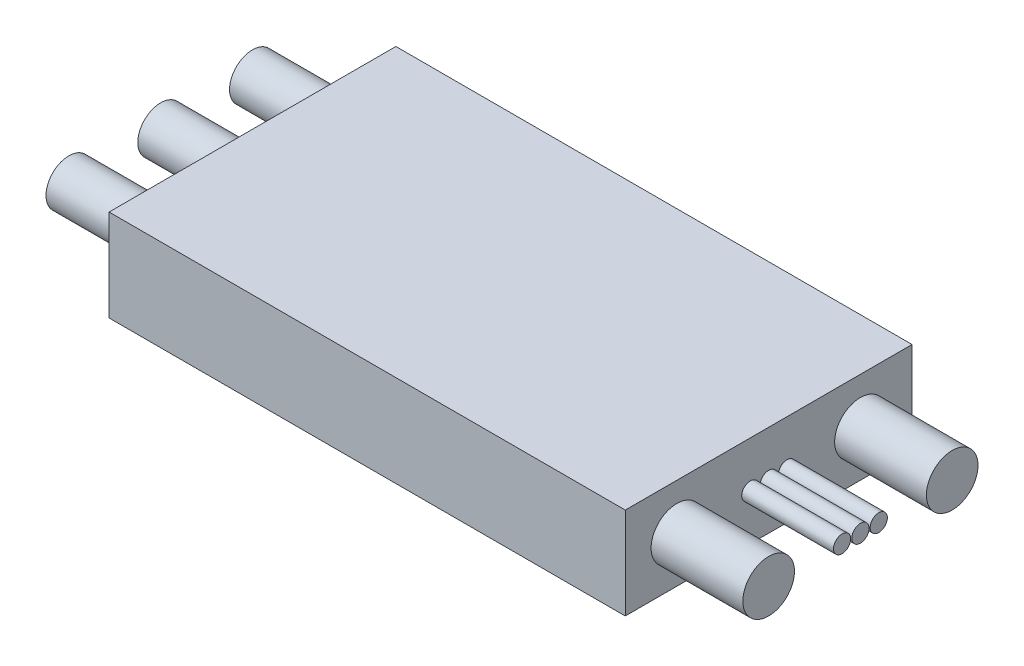
from build123d import *

# Parameters (mm, degrees)
SKETCH1_W           = 45
SKETCH1_H           = 25
BOSS_EXTRUDE1_DEPTH = 8
SKETCH2_R           = 2
BOSS_EXTRUDE2_DEPTH = 8
SKETCH3_R           = 2.25
SKETCH3_R_2         = 0.75
BOSS_EXTRUDE5_DEPTH = 8


with BuildPart() as part:
    # Sketch1 → Boss-Extrude1 (new body)
    with BuildSketch(Plane(origin=(0, 0, 0), x_dir=(1, 0, 0), z_dir=(0, 1, 0))):
        with Locations((22.5, 12.5)):
            Rectangle(SKETCH1_W, SKETCH1_H)
    extrude(amount=BOSS_EXTRUDE1_DEPTH)

    # Sketch2 → Boss-Extrude2 (add)
    with BuildSketch(Plane.ZY):
        with Locations((-12.5, 4)):
            Circle(SKETCH2_R)
        with Locations((-20.5, 4)):
            Circle(SKETCH2_R)
        with Locations((-4.5, 4)):
            Circle(SKETCH2_R)
    extrude(amount=BOSS_EXTRUDE2_DEPTH)

    # Sketch3 → Boss-Extrude5 (add)
    with BuildSketch(Plane(origin=(45, 0, 0), x_dir=(0, 0, -1), z_dir=(1, 0, 0))):
        with Locations((4.5, 4)):
            Circle(SKETCH3_R)
        with Locations((20.5, 4)):
            Circle(SKETCH3_R)
        with Locations((10.9, 4)):
            Circle(SKETCH3_R_2)
        with Locations((12.5, 4)):
            Circle(SKETCH3_R_2)
        with Locations((14.1, 4)):
            Circle(SKETCH3_R_2)
    extrude(amount=BOSS_EXTRUDE5_DEPTH)


solid = part.part
